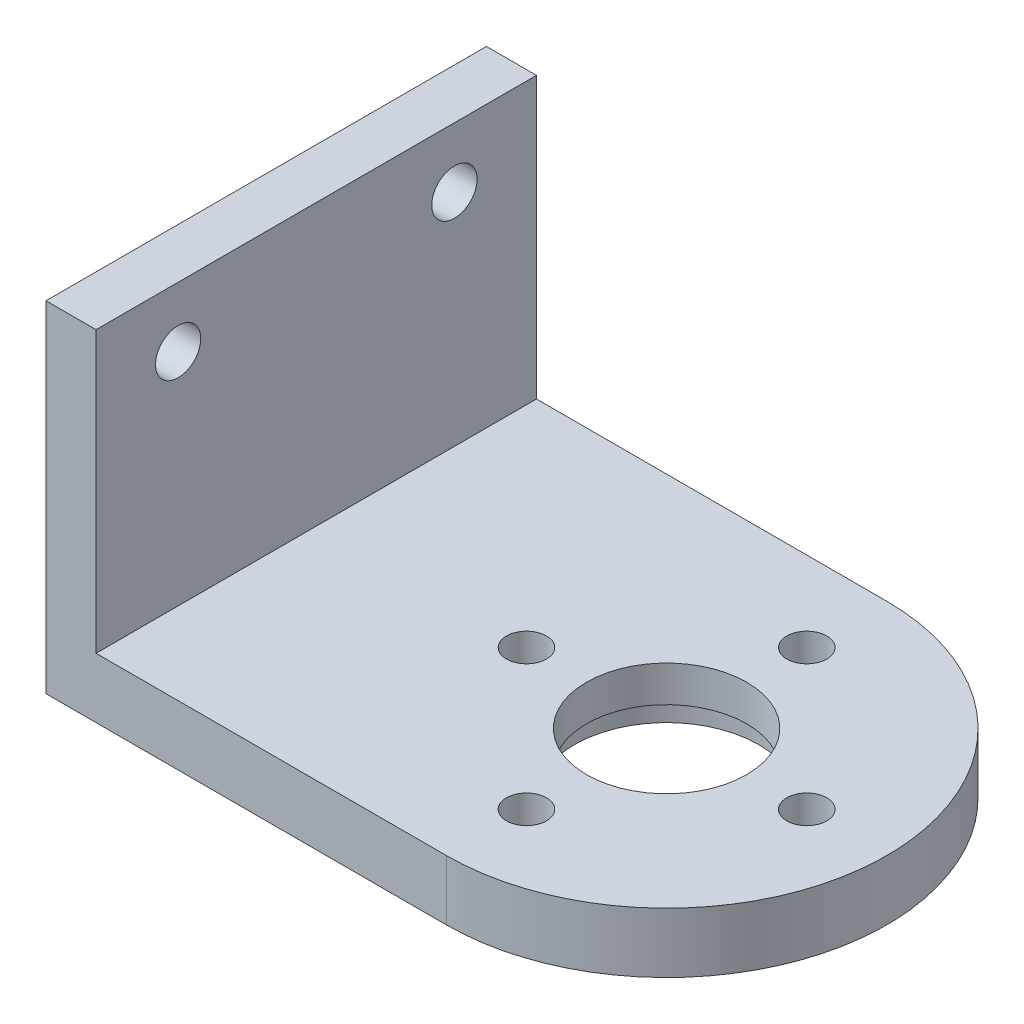
from build123d import *

# Parameters (mm, degrees)
SKETCH1_R           = 1
SKETCH1_R_2         = 4
BOSS_EXTRUDE1_DEPTH = 3
SKETCH2_W           = 2.5
SKETCH2_H           = 22
BOSS_EXTRUDE2_DEPTH = 14
SKETCH3_R           = 1.132393425
SKETCH3_R_2         = 1.130977438
CUT_EXTRUDE1_DEPTH  = 6
SKETCH4_R           = 4.6
CUT_EXTRUDE2_DEPTH  = 1.2
SKETCH5_R           = 1.9
CUT_EXTRUDE3_DEPTH  = 1.5


with BuildPart() as part:
    # Sketch1 → Boss-Extrude1 (new body)
    with BuildSketch(Plane(origin=(0, 0, 0), x_dir=(1, 0, 0), z_dir=(0, 1, 0))):
        with BuildLine():
            Line((-14, -11), (-14, 11))
            Line((-14, 11), (6, 11))
            ThreePointArc((6, 11), (17, 0), (6, -11))
            Line((6, -11), (-14, -11))
        make_face()
        with Locations((6, -7)):
            Circle(SKETCH1_R, mode=Mode.SUBTRACT)
        with Locations((-1, 0)):
            Circle(SKETCH1_R, mode=Mode.SUBTRACT)
        with Locations((6, 0)):
            Circle(SKETCH1_R_2, mode=Mode.SUBTRACT)
        with Locations((13, 0)):
            Circle(SKETCH1_R, mode=Mode.SUBTRACT)
        with Locations((6, 7)):
            Circle(SKETCH1_R, mode=Mode.SUBTRACT)
    extrude(amount=BOSS_EXTRUDE1_DEPTH)

    # Sketch2 → Boss-Extrude2 (add)
    with BuildSketch(Plane(origin=(0, 3, 0), x_dir=(1, 0, 0), z_dir=(0, 1, 0))):
        with Locations((-12.75, 0)):
            Rectangle(SKETCH2_W, SKETCH2_H)
    extrude(amount=BOSS_EXTRUDE2_DEPTH)

    # Sketch3 → Cut-Extrude1 (cut)
    with BuildSketch(Plane(origin=(-11.5, 0, 0), x_dir=(0, 0, -1), z_dir=(1, 0, 0))):
        with Locations((6.9, 14)):
            Circle(SKETCH3_R)
        with Locations((-6.9, 14)):
            Circle(SKETCH3_R_2)
    extrude(amount=-CUT_EXTRUDE1_DEPTH, mode=Mode.SUBTRACT)

    # Sketch4 → Cut-Extrude2 (cut)
    with BuildSketch(Plane.XZ):
        with Locations((6, 0)):
            Circle(SKETCH4_R)
    extrude(amount=-CUT_EXTRUDE2_DEPTH, mode=Mode.SUBTRACT)

    # Sketch5 → Cut-Extrude3 (cut)
    with BuildSketch(Plane.XZ):
        with Locations((13, 0)):
            Circle(SKETCH5_R)
        with Locations((6, -7)):
            Circle(SKETCH5_R)
        with Locations((-1, 0)):
            Circle(SKETCH5_R)
        with Locations((6, 7)):
            Circle(SKETCH5_R)
    extrude(amount=-CUT_EXTRUDE3_DEPTH, mode=Mode.SUBTRACT)


solid = part.part
